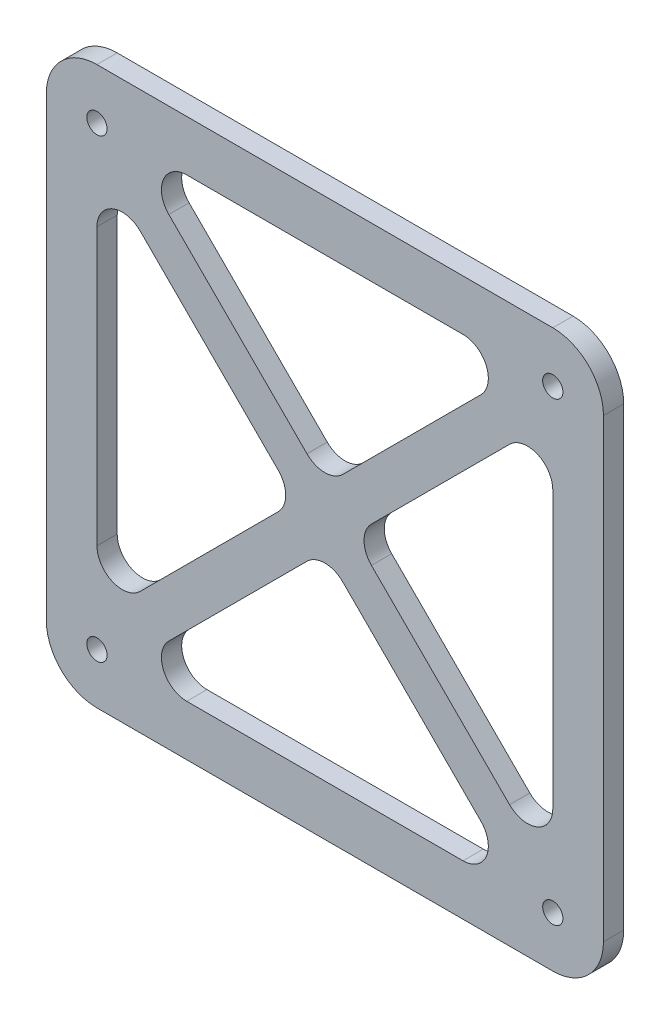
from build123d import *

# Parameters (mm, degrees)
SKETCH1_R           = 1
BOSS_EXTRUDE1_DEPTH = 2


with BuildPart() as part:
    # Sketch1 → Boss-Extrude1 (new body)
    with BuildSketch(Plane.XY):
        with BuildLine():
            Line((22.5, 27.5), (-22.5, 27.5))
            ThreePointArc((-22.5, 27.5), (-26.035533906, 26.035533906), (-27.5, 22.5))
            Line((-27.5, 22.5), (-27.5, -22.5))
            ThreePointArc((-27.5, -22.5), (-26.035533906, -26.035533906), (-22.5, -27.5))
            Line((-22.5, -27.5), (22.5, -27.5))
            ThreePointArc((22.5, -27.5), (26.035533906, -26.035533906), (27.5, -22.5))
            Line((27.5, -22.5), (27.5, 22.5))
            ThreePointArc((27.5, 22.5), (26.035533906, 26.035533906), (22.5, 27.5))
        make_face()
        with Locations((-22.5, 22.5)):
            Circle(SKETCH1_R, mode=Mode.SUBTRACT)
        with Locations((22.5, 22.5)):
            Circle(SKETCH1_R, mode=Mode.SUBTRACT)
        with Locations((22.5, -22.5)):
            Circle(SKETCH1_R, mode=Mode.SUBTRACT)
        with Locations((-22.5, -22.5)):
            Circle(SKETCH1_R, mode=Mode.SUBTRACT)
        with BuildLine():
            Line((-13.636038969, 22.5), (13.636038969, 22.5))
            ThreePointArc((13.636038969, 22.5), (15.945737801, 20.956708581), (15.403805922, 18.232233047))
            Line((15.403805922, 18.232233047), (1.767766953, 4.596194078))
            ThreePointArc((1.767766953, 4.596194078), (0, 3.863961031), (-1.767766953, 4.596194078))
            Line((-1.767766953, 4.596194078), (-15.403805922, 18.232233047))
            ThreePointArc((-15.403805922, 18.232233047), (-15.945737801, 20.956708581), (-13.636038969, 22.5))
        make_face(mode=Mode.SUBTRACT)
        with BuildLine():
            Line((-18.232233047, 15.403805922), (-4.596194078, 1.767766953))
            ThreePointArc((-4.596194078, 1.767766953), (-3.863961031, 0), (-4.596194078, -1.767766953))
            Line((-4.596194078, -1.767766953), (-18.232233047, -15.403805922))
            ThreePointArc((-18.232233047, -15.403805922), (-20.956708581, -15.945737801), (-22.5, -13.636038969))
            Line((-22.5, -13.636038969), (-22.5, 13.636038969))
            ThreePointArc((-22.5, 13.636038969), (-20.956708581, 15.945737801), (-18.232233047, 15.403805922))
        make_face(mode=Mode.SUBTRACT)
        with BuildLine():
            Line((-15.403805922, -18.232233047), (-1.767766953, -4.596194078))
            ThreePointArc((-1.767766953, -4.596194078), (0, -3.863961031), (1.767766953, -4.596194078))
            Line((1.767766953, -4.596194078), (15.403805922, -18.232233047))
            ThreePointArc((15.403805922, -18.232233047), (15.945737801, -20.956708581), (13.636038969, -22.5))
            Line((13.636038969, -22.5), (-13.636038969, -22.5))
            ThreePointArc((-13.636038969, -22.5), (-15.945737801, -20.956708581), (-15.403805922, -18.232233047))
        make_face(mode=Mode.SUBTRACT)
        with BuildLine():
            Line((18.232233047, -15.403805922), (4.596194078, -1.767766953))
            ThreePointArc((4.596194078, -1.767766953), (3.863961031, 0), (4.596194078, 1.767766953))
            Line((4.596194078, 1.767766953), (18.232233047, 15.403805922))
            ThreePointArc((18.232233047, 15.403805922), (20.956708581, 15.945737801), (22.5, 13.636038969))
            Line((22.5, 13.636038969), (22.5, -13.636038969))
            ThreePointArc((22.5, -13.636038969), (20.956708581, -15.945737801), (18.232233047, -15.403805922))
        make_face(mode=Mode.SUBTRACT)
    extrude(amount=BOSS_EXTRUDE1_DEPTH)


solid = part.part
